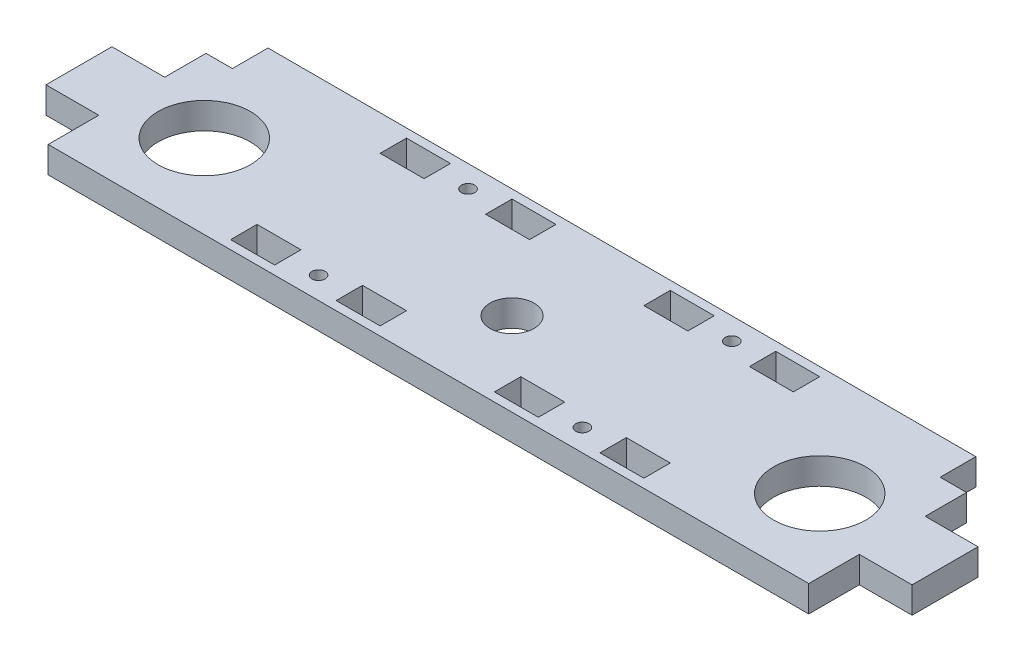
from build123d import *

# Parameters (mm, degrees)
SKETCH_1_R      = 1.5
SKETCH_1_R_2    = 10.5
SKETCH_1_R_3    = 5
SKETCH_1_W      = 10
SKETCH_1_H      = 6
EXTRUDE_1_DEPTH = 6


with BuildPart() as part:
    # Эскиз1 → Бобышка-Вытянуть1 (new body)
    with BuildSketch(Plane(origin=(0, 0, 0), x_dir=(1, 0, 0), z_dir=(0, 1, 0))):
        Polygon((90.453646354, -29.775504496), (90.453646354, -18.275504496), (102.453646354, -18.275504496), (102.453646354, -3.275504496), (90.453646354, -3.275504496), (90.453646354, 6.124495504), (84.453646354, 6.124495504), (84.453646354, 14.224495504), (-76.546353646, 14.224495504), (-76.546353646, 6.124495504), (-82.546353646, 6.124495504), (-82.546353646, -3.275504496), (-94.546353646, -3.275504496), (-94.546353646, -18.275504496), (-82.546353646, -18.275504496), (-82.546353646, -29.775504496), align=None)
        with Locations((-26.046353646, -24.775504496)):
            Circle(SKETCH_1_R, mode=Mode.SUBTRACT)
        with Locations((-66.046353646, -10.775504496)):
            Circle(SKETCH_1_R_2, mode=Mode.SUBTRACT)
        with Locations((-26.046353646, 9.224495504)):
            Circle(SKETCH_1_R, mode=Mode.SUBTRACT)
        with Locations((33.953646354, -24.775504496)):
            Circle(SKETCH_1_R, mode=Mode.SUBTRACT)
        with Locations((73.953646354, -10.775504496)):
            Circle(SKETCH_1_R_2, mode=Mode.SUBTRACT)
        with Locations((33.953646354, 9.224495504)):
            Circle(SKETCH_1_R, mode=Mode.SUBTRACT)
        with Locations((3.953646354, -10.775504496)):
            Circle(SKETCH_1_R_3, mode=Mode.SUBTRACT)
        with Locations((-14.046353646, -24.775504496)):
            Rectangle(SKETCH_1_W, SKETCH_1_H, mode=Mode.SUBTRACT)
        with Locations((-38.046353646, -24.775504496)):
            Rectangle(SKETCH_1_W, SKETCH_1_H, mode=Mode.SUBTRACT)
        with Locations((-14.046353646, 9.224495504)):
            Rectangle(SKETCH_1_W, SKETCH_1_H, mode=Mode.SUBTRACT)
        with Locations((-38.046353646, 9.224495504)):
            Rectangle(SKETCH_1_W, SKETCH_1_H, mode=Mode.SUBTRACT)
        with Locations((21.953646354, -24.775504496)):
            Rectangle(SKETCH_1_W, SKETCH_1_H, mode=Mode.SUBTRACT)
        with Locations((45.953646354, -24.775504496)):
            Rectangle(SKETCH_1_W, SKETCH_1_H, mode=Mode.SUBTRACT)
        with Locations((21.953646354, 9.224495504)):
            Rectangle(SKETCH_1_W, SKETCH_1_H, mode=Mode.SUBTRACT)
        with Locations((45.953646354, 9.224495504)):
            Rectangle(SKETCH_1_W, SKETCH_1_H, mode=Mode.SUBTRACT)
    extrude(amount=EXTRUDE_1_DEPTH)


solid = part.part
